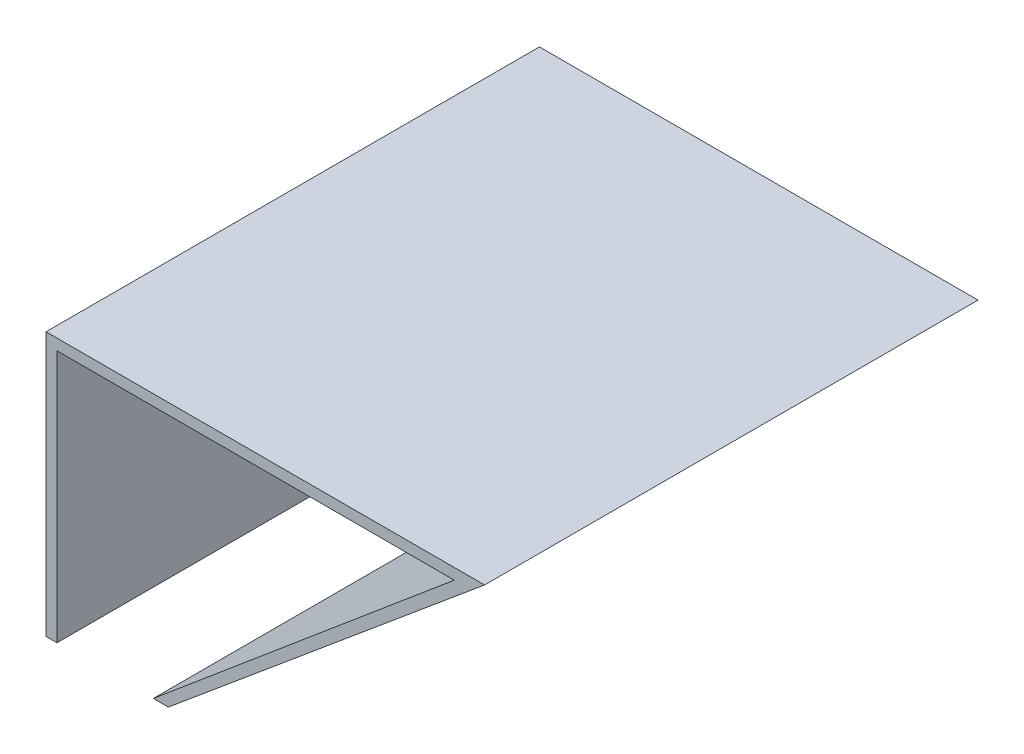
from build123d import *

# Parameters (mm, degrees)
BOSS_EXTRUDE1_DEPTH = 45


with BuildPart() as part:
    # Sketch1 → Boss-Extrude1 (new body)
    with BuildSketch(Plane.XY):
        Polygon((11.160227706, 0), (40, 24.066017178), (0, 24.066017178), (0, 0), (1, 0), (1, 23.066017178), (37.240848129, 23.066017178), (9.788165031, 0), align=None)
    extrude(amount=BOSS_EXTRUDE1_DEPTH)


solid = part.part
